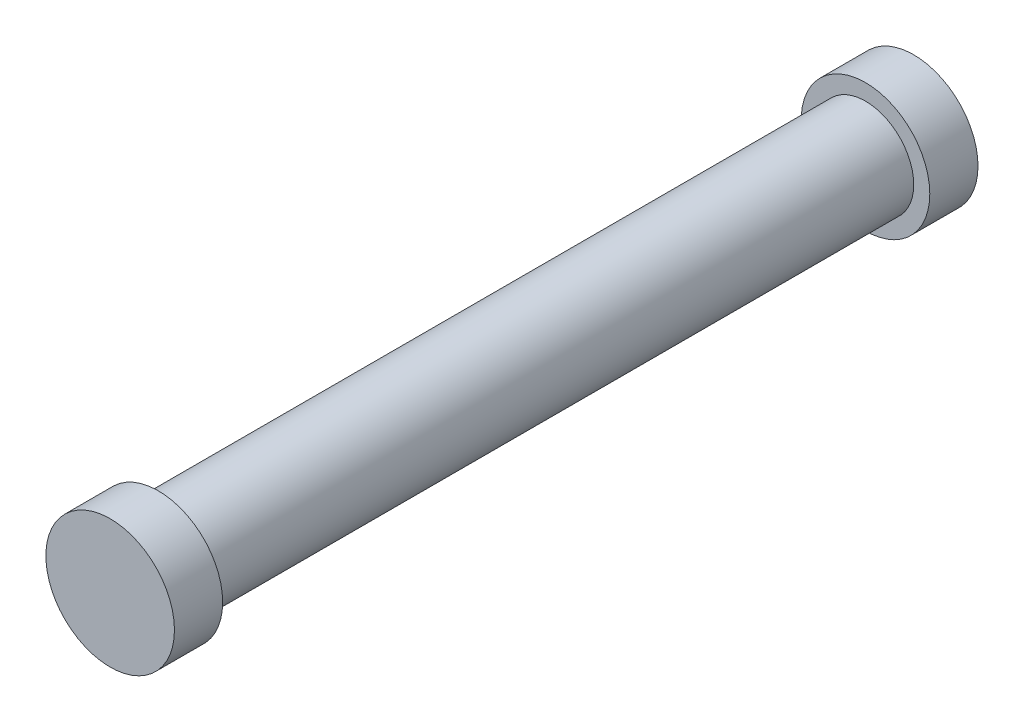
from build123d import *

# Parameters (mm, degrees)
SKETCH1_R           = 25.4
BOSS_EXTRUDE1_DEPTH = 19.05
SKETCH2_R           = 19.05
BOSS_EXTRUDE2_DEPTH = 279.4
SKETCH3_R           = 25.4
BOSS_EXTRUDE3_DEPTH = 19.05


with BuildPart() as part:
    # Sketch1 → Boss-Extrude1 (new body)
    with BuildSketch(Plane.XY):
        Circle(SKETCH1_R)
    extrude(amount=BOSS_EXTRUDE1_DEPTH)

    # Sketch2 → Boss-Extrude2 (add)
    with BuildSketch(Plane.XY.offset(19.05)):
        Circle(SKETCH2_R)
    extrude(amount=BOSS_EXTRUDE2_DEPTH)

    # Sketch3 → Boss-Extrude3 (add)
    with BuildSketch(Plane.XY.offset(298.45)):
        Circle(SKETCH3_R)
    extrude(amount=BOSS_EXTRUDE3_DEPTH)


solid = part.part
